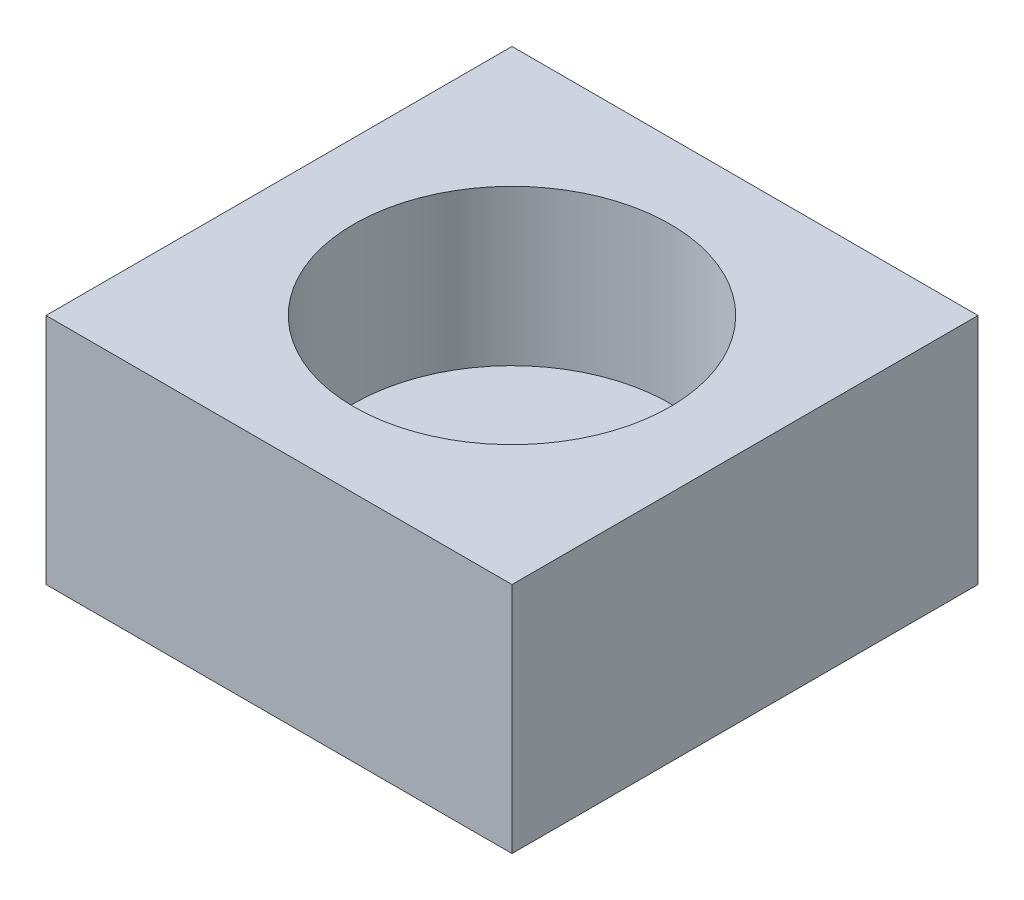
from build123d import *

# Parameters (mm, degrees)
ESQUISSE1_W             = 6
ESQUISSE1_H             = 6
EXTRUSION1_DEPTH        = 3
ESQUISSE2_R             = 2.037099296
ENL_V_MAT_EXTRU_1_DEPTH = 2


with BuildPart() as part:
    # Esquisse1 → Extrusion1 (new body)
    with BuildSketch(Plane(origin=(0, 0, 0), x_dir=(1, 0, 0), z_dir=(0, 1, 0))):
        with Locations((3, 3)):
            Rectangle(ESQUISSE1_W, ESQUISSE1_H)
    extrude(amount=EXTRUSION1_DEPTH)

    # Esquisse2 → Enlèv. mat.-Extru.1 (cut)
    with BuildSketch(Plane(origin=(0, 3, 0), x_dir=(-1, 0, 0), z_dir=(0, 1, 0))):
        with Locations(Location((-3, -3, 0), (0, 0, 90))):  # turned: the seam where the file's is
            Circle(ESQUISSE2_R)
    extrude(amount=-ENL_V_MAT_EXTRU_1_DEPTH, mode=Mode.SUBTRACT)


solid = part.part
